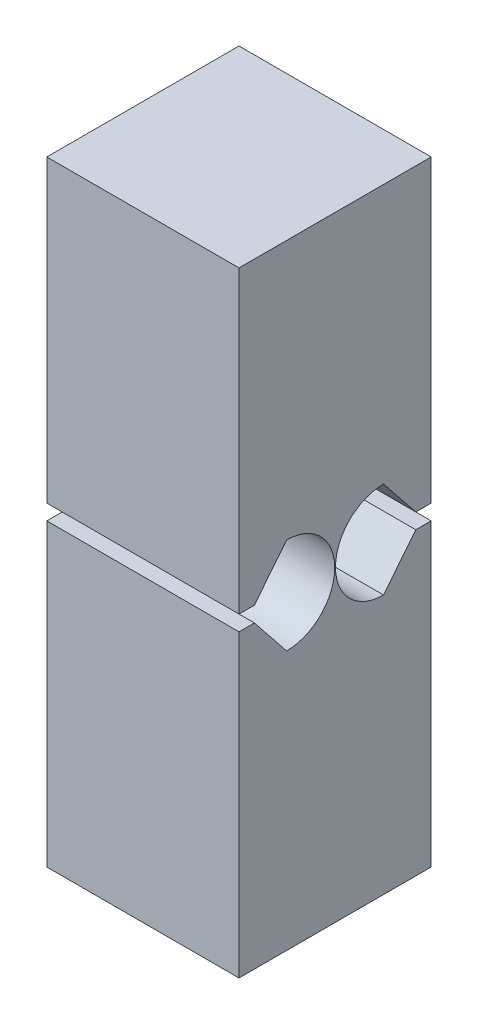
from build123d import *

# Parameters (mm, degrees)
SKETCH1_W           = 6.35
SKETCH1_H           = 6.35
BOSS_EXTRUDE1_DEPTH = 10.16
CUT_EXTRUDE1_DEPTH  = 6.35


with BuildPart() as part:
    # Sketch1 → Boss-Extrude1 (new body, symmetric)
    with BuildSketch(Plane(origin=(0, 0, 0), x_dir=(1, 0, 0), z_dir=(0, 1, 0))):
        Rectangle(SKETCH1_W, SKETCH1_H)
    extrude(amount=BOSS_EXTRUDE1_DEPTH, both=True)

    # Sketch2 → Cut-Extrude1 (cut)
    with BuildSketch(Plane(origin=(3.175, 0, 0), x_dir=(0, 0, -1), z_dir=(1, 0, 0))):
        with BuildLine():
            Line((-3.175, 0.254), (-3.175, -0.254))
            Line((-3.175, -0.254), (-2.667, -0.254))
            Line((-2.667, -0.254), (-1.6002, -1.5875))
            ThreePointArc((-1.6002, -1.5875), (-0.0127, 0), (-1.6002, 1.5875))
            Line((-1.6002, 1.5875), (-2.667, 0.254))
            Line((-2.667, 0.254), (-3.175, 0.254))
        make_face()
    cut_extrude1 = extrude(amount=-CUT_EXTRUDE1_DEPTH, mode=Mode.SUBTRACT)

    # Mirror1: Cut-Extrude1 across plane
    add(cut_extrude1.mirror(Plane.XY), mode=Mode.SUBTRACT)


solid = part.part
